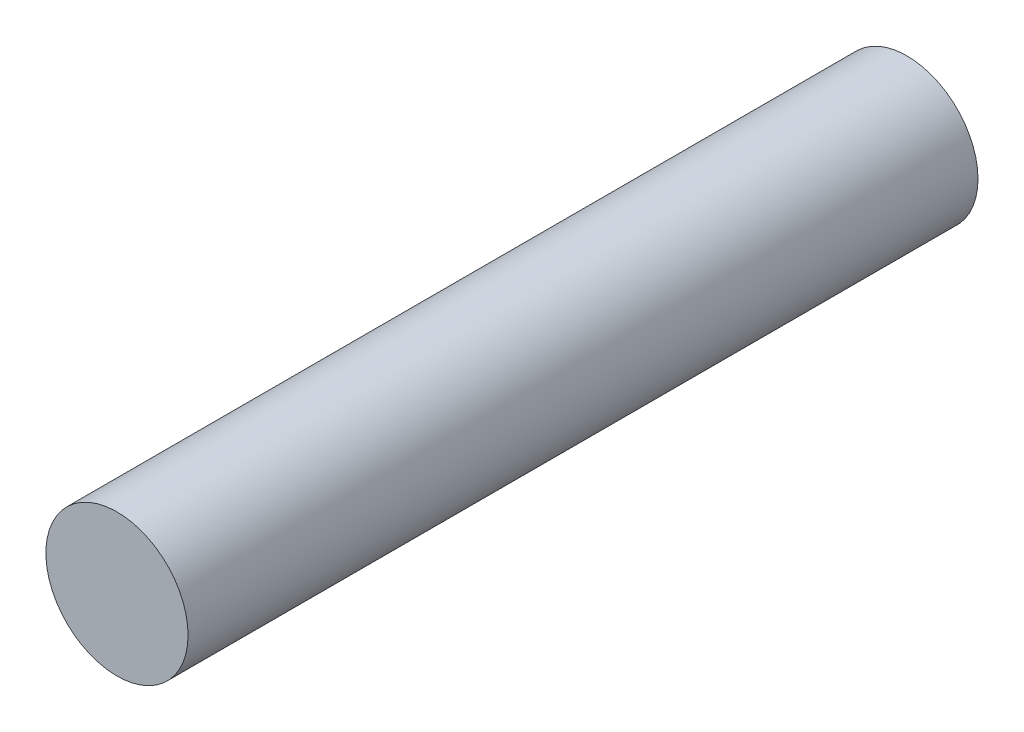
from build123d import *

# Parameters (mm, degrees)
ESQUISSE1_R        = 1.8
BOSS_EXTRU_2_DEPTH = 20


with BuildPart() as part:
    # Esquisse1 → Boss.-Extru.2 (new body)
    with BuildSketch(Plane.XY):
        with Locations((-2.13919775, 7.058404164)):
            Circle(ESQUISSE1_R)
    extrude(amount=BOSS_EXTRU_2_DEPTH)


solid = part.part
